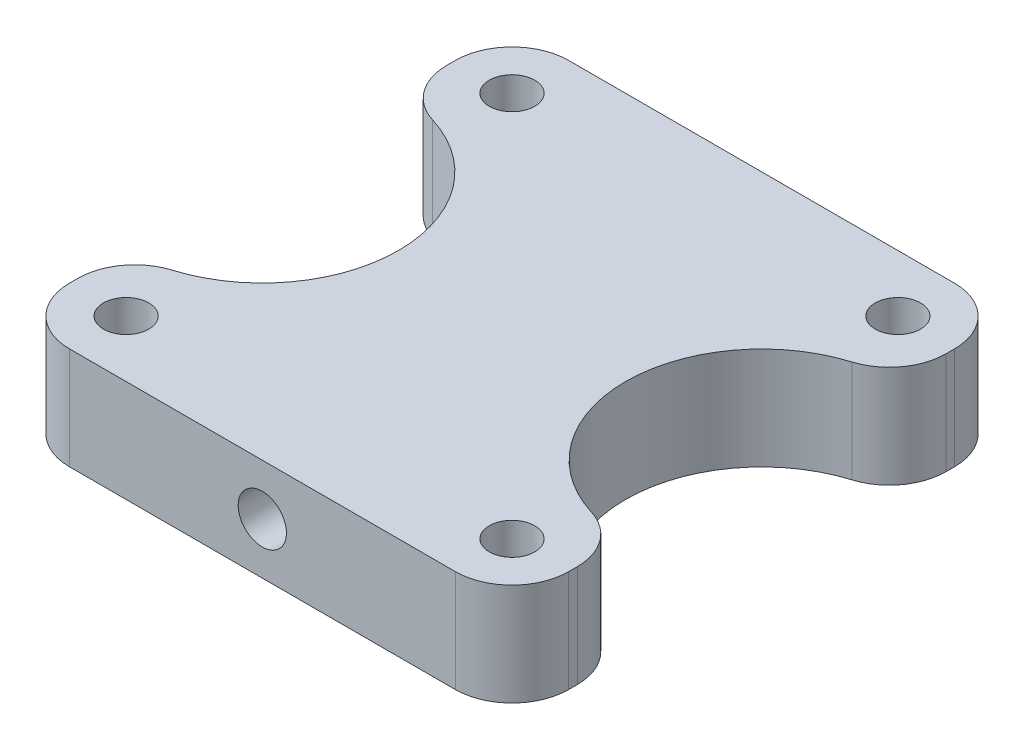
from build123d import *

# Parameters (mm, degrees)
SKETCH1_W           = 88
SKETCH1_H           = 88
BOSS_EXTRUDE1_DEPTH = 18
FILLET1_R           = 10
SKETCH2_R           = 2.15
CUT_EXTRUDE1_DEPTH  = 19
SKETCH5_R           = 4
CUT_EXTRUDE4_DEPTH  = 13
SKETCH6_R           = 4.25
CUT_EXTRUDE5_DEPTH  = 40
CHAMFER1_SIZE       = 20
CHAMFER1_SIZE2      = 0.349101299
SKETCH7_R           = 24
CUT_EXTRUDE6_DEPTH  = 19
FILLET2_R           = 10


with BuildPart() as part:
    # Sketch1 → Boss-Extrude1 (new body)
    with BuildSketch(Plane(origin=(0, 0, 0), x_dir=(1, 0, 0), z_dir=(0, 1, 0))):
        Rectangle(SKETCH1_W, SKETCH1_H)
    extrude(amount=BOSS_EXTRUDE1_DEPTH)

    # Fillet1
    fillet1_edges = [part.edges().sort_by_distance(p)[0] for p in [
        (-44, 9, -44),
        (-44, 9, 44),
        (44, 9, 44),
        (44, 9, -44),
    ]]
    fillet(fillet1_edges, radius=FILLET1_R)

    # Sketch2 → Cut-Extrude1 (cut, through all)
    with BuildSketch(Plane(origin=(0, 18, 0), x_dir=(1, 0, 0), z_dir=(0, 1, 0))):
        with Locations((-34, 34)):
            Circle(SKETCH2_R)
        with Locations((34, 34)):
            Circle(SKETCH2_R)
        with Locations((34, -34)):
            Circle(SKETCH2_R)
        with Locations((-34, -34)):
            Circle(SKETCH2_R)
    extrude(amount=-CUT_EXTRUDE1_DEPTH, mode=Mode.SUBTRACT)

    # Sketch5 → Cut-Extrude4 (cut)
    with BuildSketch(Plane(origin=(0, 18, 0), x_dir=(1, 0, 0), z_dir=(0, 1, 0))):
        with Locations((-34, 34)):
            Circle(SKETCH5_R)
        with Locations((34, 34)):
            Circle(SKETCH5_R)
        with Locations((34, -34)):
            Circle(SKETCH5_R)
        with Locations((-34, -34)):
            Circle(SKETCH5_R)
    extrude(amount=-CUT_EXTRUDE4_DEPTH, mode=Mode.SUBTRACT)

    # Sketch6 → Cut-Extrude5 (cut)
    with BuildSketch(Plane.XY.offset(44)):
        with Locations((0, 9)):
            Circle(SKETCH6_R)
    extrude(amount=-CUT_EXTRUDE5_DEPTH, mode=Mode.SUBTRACT)

    # Chamfer1
    chamfer1_edges = [part.edges().sort_by_distance(p)[0] for p in [
        (-4.25, 9, 4),
    ]]
    chamfer1_side = [part.faces().sort_by_distance(p)[0] for p in [
        (-4.25, 9, 24),
    ]]
    chamfer(chamfer1_edges, length=CHAMFER1_SIZE, length2=CHAMFER1_SIZE2, reference=chamfer1_side[0])

    # Sketch7 → Cut-Extrude6 (cut, through all)
    with BuildSketch(Plane(origin=(0, 18, 0), x_dir=(1, 0, 0), z_dir=(0, 1, 0))):
        with Locations((-44, 0)):
            Circle(SKETCH7_R)
        with Locations((44, 0)):
            Circle(SKETCH7_R)
    extrude(amount=-CUT_EXTRUDE6_DEPTH, mode=Mode.SUBTRACT)

    # Fillet2
    fillet2_edges = [part.edges().sort_by_distance(p)[0] for p in [
        (-44, 9, 24),
        (-44, 9, -24),
        (44, 9, 24),
        (44, 9, -24),
    ]]
    fillet(fillet2_edges, radius=FILLET2_R)


solid = part.part
